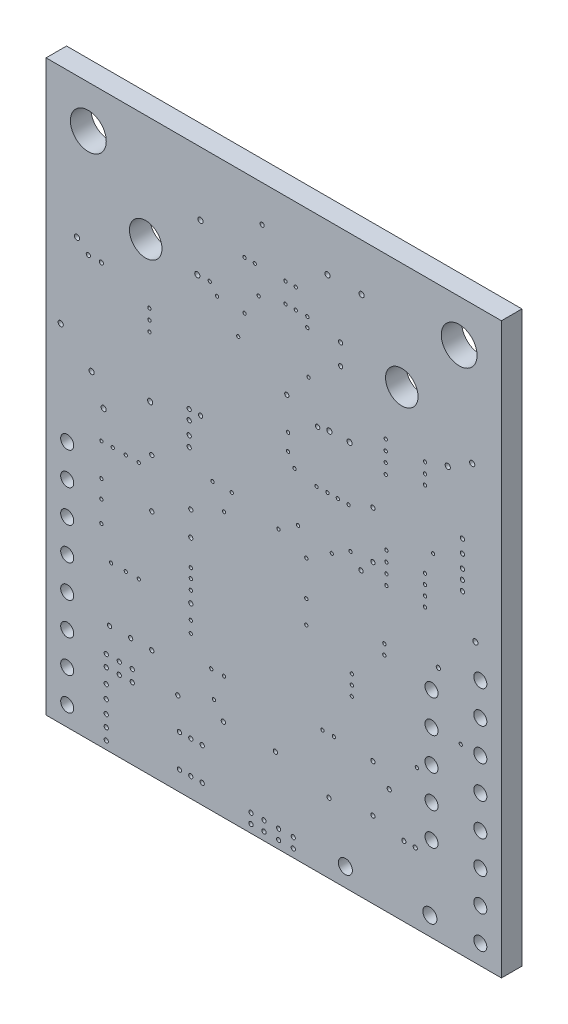
from build123d import *

# Parameters (mm, degrees)
SKETCH1_W           = 35.56
SKETCH1_H           = 44.45
BOARD_OUTLINE_DEPTH = 1.6
SKETCH2_R           = 0.127
SKETCH2_R_2         = 0.2032
SKETCH2_R_3         = 0.1651
NPTH_DEPTH          = 2.6
SKETCH3_R           = 1.4
SKETCH3_R_2         = 0.51
SKETCH3_R_3         = 1.27
SKETCH3_R_4         = 0.55
PTH_DEPTH           = 2.6


with BuildPart() as part:
    # Sketch1 → Board_Outline (new body)
    with BuildSketch(Plane.XY):
        with Locations((17.78, 22.225)):
            Rectangle(SKETCH1_W, SKETCH1_H)
    extrude(amount=BOARD_OUTLINE_DEPTH)

    # Sketch2 → NPTH (cut, through all)
    with BuildSketch(Plane.XY):
        with Locations((29.591, 23.622)):
            Circle(SKETCH2_R)
        with Locations((32.385, 14.224)):
            Circle(SKETCH2_R)
        with Locations((20.32, 18.034)):
            Circle(SKETCH2_R)
        with Locations((13.111, 7.6)):
            Circle(SKETCH2_R)
        with Locations((18.7, 37.15)):
            Circle(SKETCH2_R)
        with Locations((19.676, 22.67)):
            Circle(SKETCH2_R)
        with Locations((16.3, 38.7)):
            Circle(SKETCH2_R)
        with Locations((18.149, 21.651)):
            Circle(SKETCH2_R)
        with Locations((18.7, 38.7)):
            Circle(SKETCH2_R)
        with Locations((20.322, 20.778)):
            Circle(SKETCH2_R)
        with Locations((12.78, 35.731)):
            Circle(SKETCH2_R)
        with Locations((19.5, 37.15)):
            Circle(SKETCH2_R)
        with Locations((13, 22.3)):
            Circle(SKETCH2_R)
        with Locations((13.35, 35)):
            Circle(SKETCH2_R)
        with Locations((20.4, 37.15)):
            Circle(SKETCH2_R)
        with Locations((18.9, 28.573)):
            Circle(SKETCH2_R)
        with Locations((15.5, 38.7)):
            Circle(SKETCH2_R)
        with Locations((14.5, 22.3)):
            Circle(SKETCH2_R)
        with Locations((19.5, 38.7)):
            Circle(SKETCH2_R)
        with Locations((13.9, 20.7)):
            Circle(SKETCH2_R)
        with Locations((15.5, 34.925)):
            Circle(SKETCH2_R)
        with Locations((12.899, 9.58)):
            Circle(SKETCH2_R)
        with Locations((16.6, 36.65)):
            Circle(SKETCH2_R)
        with Locations((13.899, 9.58)):
            Circle(SKETCH2_R)
        with Locations((20.4, 36.4)):
            Circle(SKETCH2_R)
        with Locations((18.9, 27.273)):
            Circle(SKETCH2_R)
        with Locations((22.311, 22.097)):
            Circle(SKETCH2_R)
        with Locations((20.5, 33.1)):
            Circle(SKETCH2_R)
        with Locations((19.399, 26.384)):
            Circle(SKETCH2_R)
        with Locations((4.318, 20.701)):
            Circle(SKETCH2_R)
        with Locations((4.318, 16.764)):
            Circle(SKETCH2_R)
        with Locations((5.08, 12.827)):
            Circle(SKETCH2_R)
        with Locations((31.369, 32.512)):
            Circle(SKETCH2_R_2)
        with Locations((8.255, 21.717)):
            Circle(SKETCH2_R_3)
        with Locations((5.207, 20.701)):
            Circle(SKETCH2_R)
        with Locations((7.239, 12.827)):
            Circle(SKETCH2_R)
        with Locations((30.634, 18.515)):
            Circle(SKETCH2_R_3)
        with Locations((24.592, 22.079)):
            Circle(SKETCH2_R_3)
        with Locations((33.528, 21.717)):
            Circle(SKETCH2_R_2)
        with Locations((4.318, 18.161)):
            Circle(SKETCH2_R)
        with Locations((4.318, 15.113)):
            Circle(SKETCH2_R)
        with Locations((17.018, 0.635)):
            Circle(SKETCH2_R_3)
        with Locations((16.002, 0.635)):
            Circle(SKETCH2_R_3)
        with Locations((32.512, 24.638)):
            Circle(SKETCH2_R_3)
        with Locations((32.512, 25.4)):
            Circle(SKETCH2_R_3)
        with Locations((28.829, 5.461)):
            Circle(SKETCH2_R_3)
        with Locations((27.94, 5.461)):
            Circle(SKETCH2_R_3)
        with Locations((16.002, 1.397)):
            Circle(SKETCH2_R_3)
        with Locations((17.018, 1.397)):
            Circle(SKETCH2_R_3)
        with Locations((4.699, 0.635)):
            Circle(SKETCH2_R_3)
        with Locations((4.699, 1.524)):
            Circle(SKETCH2_R_3)
        with Locations((4.699, 2.413)):
            Circle(SKETCH2_R_3)
        with Locations((6.223, 12.827)):
            Circle(SKETCH2_R)
        with Locations((7.239, 20.701)):
            Circle(SKETCH2_R)
        with Locations((11.303, 17.653)):
            Circle(SKETCH2_R_3)
        with Locations((6.223, 20.701)):
            Circle(SKETCH2_R)
        with Locations((11.176, 26.289)):
            Circle(SKETCH2_R_3)
        with Locations((12.065, 26.289)):
            Circle(SKETCH2_R_3)
        with Locations((6.604, 8.509)):
            Circle(SKETCH2_R_3)
        with Locations((8.255, 8.509)):
            Circle(SKETCH2_R_3)
        with Locations((10.287, 6.477)):
            Circle(SKETCH2_R_3)
        with Locations((17.907, 6.477)):
            Circle(SKETCH2_R_3)
        with Locations((1.143, 27.051)):
            Circle(SKETCH2_R_2)
        with Locations((4.4958, 22.987)):
            Circle(SKETCH2_R_2)
        with Locations((25.527, 26.797)):
            Circle(SKETCH2_R_3)
        with Locations((25.527, 5.969)):
            Circle(SKETCH2_R_3)
        with Locations((32.512, 26.162)):
            Circle(SKETCH2_R_3)
        with Locations((12.192, 4.064)):
            Circle(SKETCH2_R_3)
        with Locations((12.192, 1.524)):
            Circle(SKETCH2_R_3)
        with Locations((10.414, 1.524)):
            Circle(SKETCH2_R_3)
        with Locations((10.414, 4.064)):
            Circle(SKETCH2_R_3)
        with Locations((11.303, 4.064)):
            Circle(SKETCH2_R_3)
        with Locations((11.303, 1.524)):
            Circle(SKETCH2_R_3)
        with Locations((16.873, 41.6)):
            Circle(SKETCH2_R_3)
        with Locations((23, 35.1)):
            Circle(SKETCH2_R_3)
        with Locations((22.127, 30.273)):
            Circle(SKETCH2_R_2)
        with Locations((18.8, 31.0635)):
            Circle(SKETCH2_R_3)
        with Locations((11.303, 13.208)):
            Circle(SKETCH2_R_3)
        with Locations((26.5746, 23.641)):
            Circle(SKETCH2_R)
        with Locations((21.209, 30.099)):
            Circle(SKETCH2_R_3)
        with Locations((11.176, 25.527)):
            Circle(SKETCH2_R_3)
        with Locations((24.638, 40.767)):
            Circle(SKETCH2_R_2)
        with Locations((11.811, 35.687)):
            Circle(SKETCH2_R_2)
        with Locations((21.59, 9.779)):
            Circle(SKETCH2_R)
        with Locations((22.479, 9.779)):
            Circle(SKETCH2_R)
        with Locations((11.303, 14.097)):
            Circle(SKETCH2_R)
        with Locations((8.071, 29.953)):
            Circle(SKETCH2_R)
        with Locations((11.303, 14.883)):
            Circle(SKETCH2_R)
        with Locations((8.071, 30.753)):
            Circle(SKETCH2_R)
        with Locations((11.303, 15.621)):
            Circle(SKETCH2_R)
        with Locations((8.071, 31.553)):
            Circle(SKETCH2_R)
        with Locations((23, 36.7)):
            Circle(SKETCH2_R_3)
        with Locations((3.556, 25.019)):
            Circle(SKETCH2_R_2)
        with Locations((2.413, 33.528)):
            Circle(SKETCH2_R_2)
        with Locations((20.32, 16.256)):
            Circle(SKETCH2_R)
        with Locations((29.591, 24.384)):
            Circle(SKETCH2_R)
        with Locations((19.304, 0.635)):
            Circle(SKETCH2_R_3)
        with Locations((19.304, 1.397)):
            Circle(SKETCH2_R_3)
        with Locations((18.161, 1.397)):
            Circle(SKETCH2_R_3)
        with Locations((18.161, 0.635)):
            Circle(SKETCH2_R_3)
        with Locations((30.226, 26.035)):
            Circle(SKETCH2_R)
        with Locations((21.117, 26.019)):
            Circle(SKETCH2_R)
        with Locations((29.591, 22.86)):
            Circle(SKETCH2_R)
        with Locations((26.416, 17.272)):
            Circle(SKETCH2_R)
        with Locations((29.591, 22.098)):
            Circle(SKETCH2_R)
        with Locations((26.416, 18.034)):
            Circle(SKETCH2_R)
        with Locations((22.7838, 26.035)):
            Circle(SKETCH2_R)
        with Locations((29.591, 31.115)):
            Circle(SKETCH2_R)
        with Locations((21.971, 26.035)):
            Circle(SKETCH2_R)
        with Locations((29.591, 30.353)):
            Circle(SKETCH2_R)
        with Locations((29.591, 31.9278)):
            Circle(SKETCH2_R)
        with Locations((23.622, 26.035)):
            Circle(SKETCH2_R)
        with Locations((11.303, 11.176)):
            Circle(SKETCH2_R)
        with Locations((11.303, 12.065)):
            Circle(SKETCH2_R)
        with Locations((23.78, 22.956)):
            Circle(SKETCH2_R)
        with Locations((23.876, 13.208)):
            Circle(SKETCH2_R)
        with Locations((23.876, 13.97)):
            Circle(SKETCH2_R)
        with Locations((28.956, 10.922)):
            Circle(SKETCH2_R)
        with Locations((23.876, 14.732)):
            Circle(SKETCH2_R)
        with Locations((22.098, 5.461)):
            Circle(SKETCH2_R_3)
        with Locations((26.797, 8.382)):
            Circle(SKETCH2_R_3)
        with Locations((11.303, 19.558)):
            Circle(SKETCH2_R_3)
        with Locations((25.527, 23.114)):
            Circle(SKETCH2_R_3)
        with Locations((32.512, 27.178)):
            Circle(SKETCH2_R_3)
        with Locations((32.512, 28.194)):
            Circle(SKETCH2_R_3)
        with Locations((5.715, 6.477)):
            Circle(SKETCH2_R_3)
        with Locations((4.699, 6.477)):
            Circle(SKETCH2_R_3)
        with Locations((6.731, 6.477)):
            Circle(SKETCH2_R_3)
        with Locations((11.176, 24.511)):
            Circle(SKETCH2_R_3)
        with Locations((8.255, 17.907)):
            Circle(SKETCH2_R_3)
        with Locations((4.318, 32.766)):
            Circle(SKETCH2_R_3)
        with Locations((11.176, 23.711)):
            Circle(SKETCH2_R_3)
        with Locations((6.731, 5.588)):
            Circle(SKETCH2_R_3)
        with Locations((5.715, 5.588)):
            Circle(SKETCH2_R_3)
        with Locations((4.953, 8.509)):
            Circle(SKETCH2_R_3)
        with Locations((13.843, 6.477)):
            Circle(SKETCH2_R_3)
        with Locations((25.527, 9.652)):
            Circle(SKETCH2_R_3)
        with Locations((4.699, 3.429)):
            Circle(SKETCH2_R_3)
        with Locations((4.699, 4.445)):
            Circle(SKETCH2_R_3)
        with Locations((4.699, 5.588)):
            Circle(SKETCH2_R_3)
        with Locations((3.302, 32.766)):
            Circle(SKETCH2_R_3)
        with Locations((15, 33.1)):
            Circle(SKETCH2_R)
        with Locations((26.5746, 22.041)):
            Circle(SKETCH2_R)
        with Locations((26.5746, 22.841)):
            Circle(SKETCH2_R)
        with Locations((26.5746, 24.441)):
            Circle(SKETCH2_R)
        with Locations((26.524, 31.934)):
            Circle(SKETCH2_R)
        with Locations((26.524, 31.134)):
            Circle(SKETCH2_R)
        with Locations((26.524, 30.334)):
            Circle(SKETCH2_R)
        with Locations((26.524, 29.534)):
            Circle(SKETCH2_R)
        with Locations((33.274, 33.655)):
            Circle(SKETCH2_R_2)
        with Locations((23.7, 30.304)):
            Circle(SKETCH2_R_2)
        with Locations((21.971, 40.767)):
            Circle(SKETCH2_R_2)
        with Locations((8.128, 25.273)):
            Circle(SKETCH2_R_2)
        with Locations((12.065, 39.497)):
            Circle(SKETCH2_R_2)
    extrude(amount=NPTH_DEPTH, mode=Mode.SUBTRACT)

    # Sketch3 → PTH (cut, through all)
    with BuildSketch(Plane.XY):
        with Locations((3.3, 41.15)):
            Circle(SKETCH3_R)
        with Locations((32.26, 41.15)):
            Circle(SKETCH3_R)
        with Locations((33.91, 19.3)):
            Circle(SKETCH3_R_2)
        with Locations((33.91, 16.76)):
            Circle(SKETCH3_R_2)
        with Locations((33.91, 14.22)):
            Circle(SKETCH3_R_2)
        with Locations((33.91, 11.68)):
            Circle(SKETCH3_R_2)
        with Locations((33.91, 9.14)):
            Circle(SKETCH3_R_2)
        with Locations((33.91, 6.6)):
            Circle(SKETCH3_R_2)
        with Locations((33.91, 4.06)):
            Circle(SKETCH3_R_2)
        with Locations((33.91, 1.52)):
            Circle(SKETCH3_R_2)
        with Locations((1.65, 19.3)):
            Circle(SKETCH3_R_2)
        with Locations((1.65, 16.76)):
            Circle(SKETCH3_R_2)
        with Locations((1.65, 14.22)):
            Circle(SKETCH3_R_2)
        with Locations((1.65, 11.68)):
            Circle(SKETCH3_R_2)
        with Locations((1.65, 9.14)):
            Circle(SKETCH3_R_2)
        with Locations((1.65, 6.6)):
            Circle(SKETCH3_R_2)
        with Locations((1.65, 4.06)):
            Circle(SKETCH3_R_2)
        with Locations((1.65, 1.52)):
            Circle(SKETCH3_R_2)
        with Locations((30.1, 16.76)):
            Circle(SKETCH3_R_2)
        with Locations((30.1, 14.22)):
            Circle(SKETCH3_R_2)
        with Locations((30.1, 11.68)):
            Circle(SKETCH3_R_2)
        with Locations((30.1, 9.14)):
            Circle(SKETCH3_R_2)
        with Locations((30.1, 6.6)):
            Circle(SKETCH3_R_2)
        with Locations((7.78, 36.07)):
            Circle(SKETCH3_R_3)
        with Locations((27.78, 36.07)):
            Circle(SKETCH3_R_3)
        with Locations((23.37, 1.45)):
            Circle(SKETCH3_R_4)
        with Locations((29.97, 1.45)):
            Circle(SKETCH3_R_4)
    extrude(amount=PTH_DEPTH, mode=Mode.SUBTRACT)


solid = part.part
